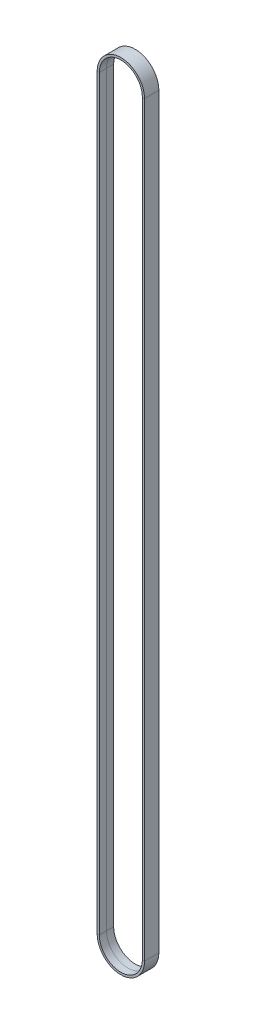
from build123d import *


with BuildPart() as part:
    # ｽｲｰﾌﾟ1: sweep along a path in ｽｹｯﾁ2
    with BuildLine(Plane.XY) as sweep_1_path:
        Line((-91.813501319, 0), (-91.813501319, 468.89420214))
        ThreePointArc((-91.813501319, 468.89420214), (-78.313501319, 482.39420214), (-64.813501319, 468.89420214))
        Line((-64.813501319, 468.89420214), (-64.813501319, 0))
        ThreePointArc((-64.813501319, 0), (-78.313501319, -13.5), (-91.813501319, 0))
    # Sketch 3D_4 → ｽｲｰﾌﾟ1 (sweep)
    with BuildSketch(Plane(origin=(-64.813501319, 1e-09, 0), x_dir=(0.2892988463727858, 0, -0.9572388299099527), z_dir=(0, -1, 0))):
        Polygon((0, 0), (4.307574735, -1.301844809), (4.701021166, 0), (-3.914128304, 2.603689617), (-4.307574735, 1.301844809), align=None)
    sweep(path=sweep_1_path.line)


solid = part.part
